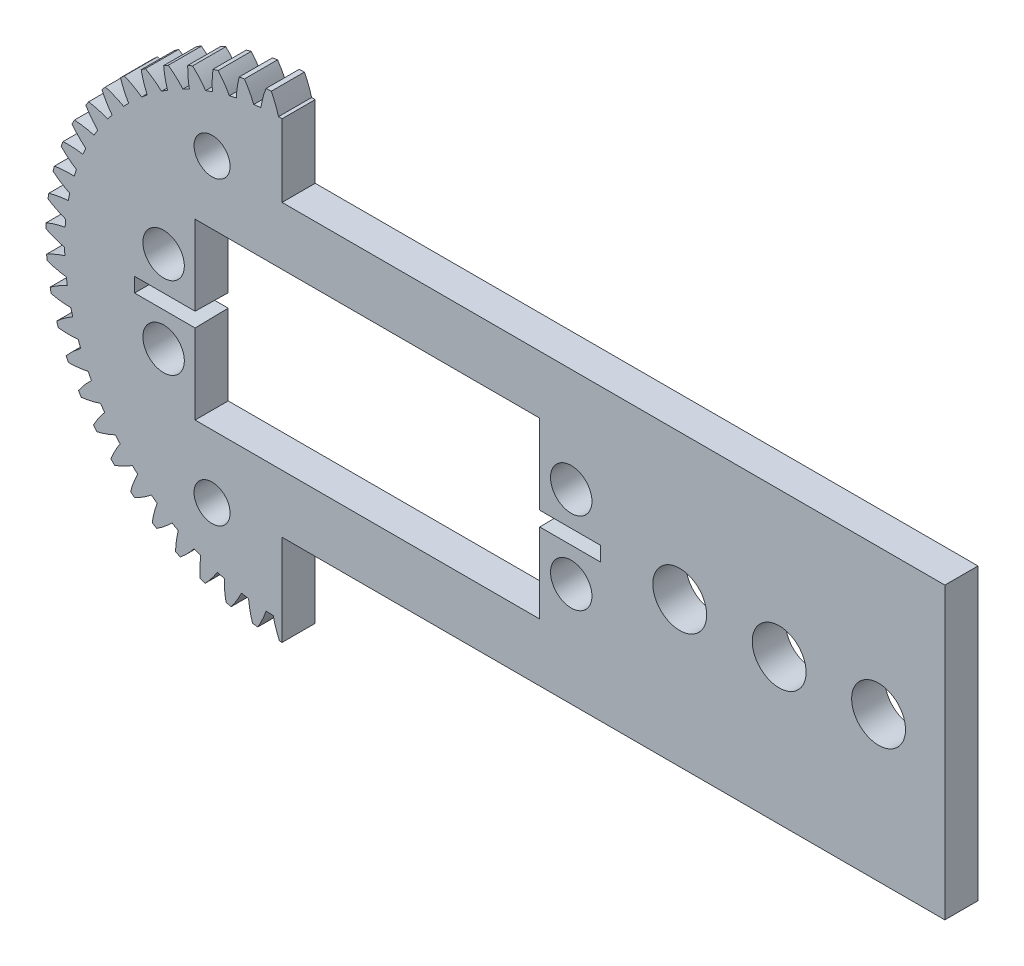
from build123d import *

# Parameters (mm, degrees)
MODEL_R                 = 2.5
BOSS_EXTRUDE1_DEPTH     = 4
SKETCH2_W               = 43.829603181
SKETCH2_H               = 63.068349784
CUT_EXTRUDE2_DEPTH      = 4
SKETCH4_W               = 80
SKETCH4_H               = 35
BOSS_EXTRUDE3_DEPTH     = 4
SKETCH5_W               = 41.6
SKETCH5_H               = 21
CUT_EXTRUDE3_DEPTH      = 4
SKETCH6_R               = 2.5
CUT_EXTRUDE4_DEPTH      = 4
SKETCH7_R               = 2.175
CUT_EXTRUDE5_DEPTH      = 4
SKETCH8_R               = 3.25
CUT_EXTRUDE6_DEPTH      = 400
LPATTERN1_COUNT         = 3
LPATTERN1_PITCH         = 12
SKETCH9_W               = 9
SKETCH9_H               = 1.75
CUT_EXTRUDE_THIN1_DEPTH = 5
CUT_EXTRUDE_THIN1_TAPER = 1


with BuildPart() as part:
    # Model → Boss-Extrude1 (new body)
    with BuildSketch(Plane.XY):
        with BuildLine():
            ThreePointArc((-28.477434739, 1.133891841), (-28.488377496, 0.813847448), (-28.495723539, 0.493700304))
            ThreePointArc((-28.495723539, 0.493700304), (-27.393467785, 0.027569431), (-26.247097137, -0.316058386))
            ThreePointArc((-26.247097137, -0.316058386), (-26.23829547, -0.749567777), (-26.222334246, -1.182872637))
            ThreePointArc((-26.222334246, -1.182872637), (-27.34721798, -1.591384969), (-28.421065212, -2.119682102))
            ThreePointArc((-28.421065212, -2.119682102), (-28.39545433, -2.438887742), (-28.366258465, -2.757785467))
            ThreePointArc((-28.366258465, -2.757785467), (-27.21805259, -3.095230288), (-26.03998367, -3.305941842))
            ThreePointArc((-26.03998367, -3.305941842), (-25.981823028, -3.73562219), (-25.916572812, -4.164283211))
            ThreePointArc((-25.916572812, -4.164283211), (-26.987557359, -4.698359835), (-27.994183636, -5.345622747))
            ThreePointArc((-27.994183636, -5.345622747), (-27.932352991, -5.659828299), (-27.866995832, -5.973319287))
            ThreePointArc((-27.866995832, -5.973319287), (-26.687808456, -6.177678948), (-25.493399194, -6.25272729))
            ThreePointArc((-25.493399194, -6.25272729), (-25.386637789, -6.672977054), (-25.272949217, -7.091405986))
            ThreePointArc((-25.272949217, -7.091405986), (-26.276072656, -7.744084395), (-27.202355065, -8.501875025))
            ThreePointArc((-27.202355065, -8.501875025), (-27.105110714, -8.80698434), (-27.004444291, -9.110981755))
            ThreePointArc((-27.004444291, -9.110981755), (-25.809647924, -9.179592114), (-24.614469271, -9.117998876))
            ThreePointArc((-24.614469271, -9.117998876), (-24.460498903, -9.523339458), (-24.29985408, -9.926081438))
            ThreePointArc((-24.29985408, -9.926081438), (-25.222039162, -10.688852972), (-26.055902194, -11.54729236))
            ThreePointArc((-26.055902194, -11.54729236), (-25.924511868, -11.839327871), (-25.78984852, -12.129868643))
            ThreePointArc((-25.78984852, -12.129868643), (-24.595019161, -12.061835259), (-23.414652099, -11.864403402))
            ThreePointArc((-23.414652099, -11.864403402), (-23.215480006, -12.249550567), (-23.009973182, -12.631355239))
            ThreePointArc((-23.009973182, -12.631355239), (-23.839197815, -13.494276004), (-24.569770792, -14.442173079))
            ThreePointArc((-24.569770792, -14.442173079), (-24.405947362, -14.717327657), (-24.239042634, -14.990624143))
            ThreePointArc((-24.239042634, -14.990624143), (-23.05975671, -14.786833935), (-21.909589129, -14.456137285))
            ThreePointArc((-21.909589129, -14.456137285), (-21.667811823, -14.816070052), (-21.420122094, -15.171960007))
            ThreePointArc((-21.420122094, -15.171960007), (-22.145576068, -16.123780511), (-22.763334852, -17.148777986))
            ThreePointArc((-22.763334852, -17.148777986), (-22.569214009, -17.40346457), (-22.372243758, -17.655953932))
            ThreePointArc((-22.372243758, -17.655953932), (-21.223875065, -17.319063617), (-20.118901158, -16.859413312))
            ThreePointArc((-20.118901158, -16.859413312), (-19.837670577, -17.189439405), (-19.551026958, -17.514775074))
            ThreePointArc((-19.551026958, -17.514775074), (-20.163252869, -18.543086881), (-20.660144031, -19.631822346))
            ThreePointArc((-20.660144031, -19.631822346), (-20.438256436, -19.862720707), (-20.213788471, -20.09111136))
            ThreePointArc((-20.213788471, -20.09111136), (-19.111307751, -19.625512819), (-18.065932542, -19.042901102))
            ThreePointArc((-18.065932542, -19.042901102), (-17.748914957, -19.338718128), (-17.427054285, -19.629258263))
            ThreePointArc((-17.427054285, -19.629258263), (-17.918070833, -20.720655756), (-18.287616636, -21.858935879))
            ThreePointArc((-18.287616636, -21.858935879), (-18.040854934, -22.063035903), (-17.791815538, -22.264350426))
            ThreePointArc((-17.791815538, -22.264350426), (-16.749595313, -21.676113448), (-15.777446868, -20.978135554))
            ThreePointArc((-15.777446868, -20.978135554), (-15.428775087, -21.235887085), (-15.075893309, -21.487844051))
            ThreePointArc((-15.075893309, -21.487844051), (-15.439299342, -22.628099195), (-15.676682192, -23.801084754))
            ThreePointArc((-15.676682192, -23.801084754), (-15.408263298, -23.975725686), (-15.13789908, -24.147339635))
            ThreePointArc((-15.13789908, -24.147339635), (-14.169526285, -23.444132788), (-13.283278045, -22.639887928))
            ThreePointArc((-13.283278045, -22.639887928), (-12.907497539, -22.856213778), (-12.528195008, -23.06630293))
            ThreePointArc((-12.528195008, -23.06630293), (-12.759252972, -24.240550755), (-12.86137822, -25.43295009))
            ThreePointArc((-12.86137822, -25.43295009), (-12.574801385, -25.575855218), (-12.286636957, -25.715531343))
            ThreePointArc((-12.286636957, -25.715531343), (-11.404735812, -24.906522005), (-10.615941378, -24.006494739))
            ThreePointArc((-10.615941378, -24.006494739), (-10.217951021, -24.178574771), (-9.817172525, -24.344057275))
            ThreePointArc((-9.817172525, -24.344057275), (-9.912870228, -25.536989666), (-9.878406515, -26.733258027))
            ThreePointArc((-9.878406515, -26.733258027), (-9.577407707, -26.842564364), (-9.275199732, -26.948481774))
            ThreePointArc((-9.275199732, -26.948481774), (-8.491267167, -26.044216618), (-7.810209681, -25.060140178))
            ThreePointArc((-7.810209681, -25.060140178), (-7.395197884, -25.185731064), (-6.978168185, -25.304449604))
            ThreePointArc((-6.978168185, -25.304449604), (-6.93725806, -26.500514862), (-6.766654673, -27.685057062))
            ThreePointArc((-6.766654673, -27.685057062), (-6.455157872, -27.759339633), (-6.142846094, -27.830117532))
            ThreePointArc((-6.142846094, -27.830117532), (-5.467101869, -26.842385037), (-4.902659956, -25.787088365))
            ThreePointArc((-4.902659956, -25.787088365), (-4.476037034, -25.864552837), (-4.048192751, -25.934959735))
            ThreePointArc((-4.048192751, -25.934959735), (-3.871208124, -27.11856532), (-3.56668914, -28.27593904))
            ThreePointArc((-3.56668914, -28.27593904), (-3.248755182, -28.314229457), (-2.930411062, -28.348945148))
            ThreePointArc((-2.930411062, -28.348945148), (-2.371664537, -27.290621918), (-1.931196562, -26.177862419))
            ThreePointArc((-1.931196562, -26.177862419), (-1.498524196, -26.206190609), (-1.065442934, -26.227368003))
            ThreePointArc((-1.065442934, -26.227368003), (-0.75469107, -27.383083806), (-0.320226359, -28.498200909))
            ThreePointArc((-0.320226359, -28.498200909), (0, -28.5), (0.320226359, -28.49820091))
            ThreePointArc((0.320226359, -28.49820091), (0.75469107, -27.383083806), (1.065442934, -26.227368003))
            ThreePointArc((1.065442934, -26.227368003), (1.498524196, -26.206190609), (1.931196562, -26.177862419))
            ThreePointArc((1.931196562, -26.177862419), (2.371664537, -27.290621918), (2.930411062, -28.348945148))
            ThreePointArc((2.930411062, -28.348945148), (3.248755182, -28.314229457), (3.56668914, -28.27593904))
            ThreePointArc((3.56668914, -28.27593904), (3.871208124, -27.11856532), (4.048192751, -25.934959735))
            ThreePointArc((4.048192751, -25.934959735), (4.476037034, -25.864552837), (4.902659956, -25.787088365))
            ThreePointArc((4.902659956, -25.787088365), (5.467101869, -26.842385037), (6.142846094, -27.830117532))
            ThreePointArc((6.142846094, -27.830117532), (6.455157872, -27.759339633), (6.766654673, -27.685057062))
            ThreePointArc((6.766654673, -27.685057062), (6.93725806, -26.500514862), (6.978168185, -25.304449604))
            ThreePointArc((6.978168185, -25.304449604), (7.395197884, -25.185731064), (7.810209681, -25.060140178))
            ThreePointArc((7.810209681, -25.060140178), (8.491267167, -26.044216618), (9.275199732, -26.948481774))
            ThreePointArc((9.275199732, -26.948481774), (9.577407707, -26.842564364), (9.878406515, -26.733258027))
            ThreePointArc((9.878406515, -26.733258027), (9.912870228, -25.536989666), (9.817172525, -24.344057275))
            ThreePointArc((9.817172525, -24.344057275), (10.217951021, -24.178574771), (10.615941378, -24.006494739))
            ThreePointArc((10.615941378, -24.006494739), (11.404735812, -24.906522005), (12.286636957, -25.715531343))
            ThreePointArc((12.286636957, -25.715531343), (12.574801385, -25.575855218), (12.86137822, -25.43295009))
            ThreePointArc((12.86137822, -25.43295009), (12.759252972, -24.240550755), (12.528195008, -23.06630293))
            ThreePointArc((12.528195008, -23.06630293), (12.907497539, -22.856213778), (13.283278045, -22.639887928))
            ThreePointArc((13.283278045, -22.639887928), (14.169526285, -23.444132788), (15.13789908, -24.147339635))
            ThreePointArc((15.13789908, -24.147339635), (15.408263297, -23.975725686), (15.676682191, -23.801084754))
            ThreePointArc((15.676682191, -23.801084754), (15.439299342, -22.628099195), (15.075893309, -21.487844051))
            ThreePointArc((15.075893309, -21.487844051), (15.428775087, -21.235887085), (15.777446868, -20.978135554))
            ThreePointArc((15.777446868, -20.978135554), (16.749595313, -21.676113448), (17.791815538, -22.264350426))
            ThreePointArc((17.791815538, -22.264350426), (18.040854934, -22.063035903), (18.287616636, -21.858935879))
            ThreePointArc((18.287616636, -21.858935879), (17.918070833, -20.720655756), (17.427054285, -19.629258263))
            ThreePointArc((17.427054285, -19.629258263), (17.748914957, -19.338718128), (18.065932542, -19.042901102))
            ThreePointArc((18.065932542, -19.042901102), (19.111307751, -19.625512819), (20.213788471, -20.09111136))
            ThreePointArc((20.213788471, -20.09111136), (20.438256436, -19.862720707), (20.660144031, -19.631822346))
            ThreePointArc((20.660144031, -19.631822346), (20.163252869, -18.543086881), (19.551026958, -17.514775074))
            ThreePointArc((19.551026958, -17.514775074), (19.837670577, -17.189439405), (20.118901158, -16.859413312))
            ThreePointArc((20.118901158, -16.859413312), (21.223875065, -17.319063617), (22.372243758, -17.655953932))
            ThreePointArc((22.372243758, -17.655953932), (22.569214009, -17.40346457), (22.763334852, -17.148777986))
            ThreePointArc((22.763334852, -17.148777986), (22.145576068, -16.123780511), (21.420122094, -15.171960007))
            ThreePointArc((21.420122094, -15.171960007), (21.667811823, -14.816070052), (21.909589129, -14.456137285))
            ThreePointArc((21.909589129, -14.456137285), (23.05975671, -14.786833935), (24.239042634, -14.990624143))
            ThreePointArc((24.239042634, -14.990624143), (24.405947362, -14.717327657), (24.569770792, -14.442173079))
            ThreePointArc((24.569770792, -14.442173079), (23.839197815, -13.494276004), (23.009973182, -12.631355239))
            ThreePointArc((23.009973182, -12.631355239), (23.215480006, -12.249550567), (23.414652099, -11.864403402))
            ThreePointArc((23.414652099, -11.864403402), (24.595019161, -12.061835259), (25.78984852, -12.129868643))
            ThreePointArc((25.78984852, -12.129868643), (25.924511868, -11.839327871), (26.055902194, -11.54729236))
            ThreePointArc((26.055902194, -11.54729236), (25.222039162, -10.688852972), (24.29985408, -9.926081438))
            ThreePointArc((24.29985408, -9.926081438), (24.460498903, -9.523339458), (24.614469271, -9.117998876))
            ThreePointArc((24.614469271, -9.117998876), (25.809647924, -9.179592114), (27.004444291, -9.110981756))
            ThreePointArc((27.004444291, -9.110981756), (27.105110714, -8.80698434), (27.202355065, -8.501875025))
            ThreePointArc((27.202355065, -8.501875025), (26.276072656, -7.744084395), (25.272949217, -7.091405986))
            ThreePointArc((25.272949217, -7.091405986), (25.386637789, -6.672977054), (25.493399194, -6.25272729))
            ThreePointArc((25.493399194, -6.25272729), (26.687808456, -6.177678948), (27.866995832, -5.973319287))
            ThreePointArc((27.866995832, -5.973319287), (27.932352991, -5.659828299), (27.994183636, -5.345622747))
            ThreePointArc((27.994183636, -5.345622747), (26.987557359, -4.698359835), (25.916572812, -4.164283211))
            ThreePointArc((25.916572812, -4.164283211), (25.981823028, -3.73562219), (26.03998367, -3.305941842))
            ThreePointArc((26.03998367, -3.305941842), (27.21805259, -3.095230288), (28.366258465, -2.757785467))
            ThreePointArc((28.366258465, -2.757785467), (28.39545433, -2.438887742), (28.421065212, -2.119682102))
            ThreePointArc((28.421065212, -2.119682102), (27.34721798, -1.591384969), (26.222334246, -1.182872637))
            ThreePointArc((26.222334246, -1.182872637), (26.23829547, -0.749567777), (26.247097137, -0.316058386))
            ThreePointArc((26.247097137, -0.316058386), (27.393467785, 0.027569431), (28.495723539, 0.493700304))
            ThreePointArc((28.495723539, 0.493700304), (28.488377496, 0.813847448), (28.477434739, 1.133891841))
            ThreePointArc((28.477434739, 1.133891841), (27.350365792, 1.536336033), (26.186247451, 1.813958491))
            ThreePointArc((26.186247451, 1.813958491), (26.152711603, 2.246258398), (26.112039552, 2.677945375))
            ThreePointArc((26.112039552, 2.677945375), (27.211767234, 3.150009741), (28.253703278, 3.738749937))
            ThreePointArc((28.253703278, 3.738749937), (28.209911094, 4.055972891), (28.162557353, 4.37268377))
            ThreePointArc((28.162557353, 4.37268377), (26.996959759, 4.644028546), (25.808782875, 4.787141897))
            ThreePointArc((25.808782875, 4.787141897), (25.726187146, 5.212801159), (25.636571599, 5.637038022))
            ThreePointArc((25.636571599, 5.637038022), (26.675319682, 6.231384856), (27.643352786, 6.935059247))
            ThreePointArc((27.643352786, 6.935059247), (27.563685359, 7.245222525), (27.480537963, 7.554471079))
            ThreePointArc((27.480537963, 7.554471079), (26.291607069, 7.691179044), (25.094861343, 7.697917586))
            ThreePointArc((25.094861343, 7.697917586), (24.964282496, 8.111387085), (24.826891729, 8.522643257))
            ThreePointArc((24.826891729, 8.522643257), (25.791118543, 9.23152434), (26.672628915, 10.040959454))
            ThreePointArc((26.672628915, 10.040959454), (26.558124833, 10.340019602), (26.440267734, 10.637774304))
            ThreePointArc((26.440267734, 10.637774304), (25.243503073, 10.638063262), (24.053789917, 10.508339148))
            ThreePointArc((24.053789917, 10.508339148), (23.876930246, 10.904228676), (23.693555357, 11.297142804))
            ThreePointArc((23.693555357, 11.297142804), (24.570690732, 12.111316787), (25.354186536, 13.015960398))
            ThreePointArc((25.354186536, 13.015960398), (25.206338533, 13.300018712), (25.055308181, 13.582397872))
            ThreePointArc((25.055308181, 13.582397872), (23.866311409, 13.446264056), (22.699140553, 13.181768438))
            ThreePointArc((22.699140553, 13.181768438), (22.478305695, 13.554916971), (22.251337257, 13.924366818))
            ThreePointArc((22.251337257, 13.924366818), (23.029946391, 14.833219697), (23.705213562, 15.821278393))
            ThreePointArc((23.705213562, 15.821278393), (23.525949063, 16.086631738), (23.343714368, 16.349954113))
            ThreePointArc((23.343714368, 16.349954113), (22.177985878, 16.079172235), (21.048573179, 15.683353218))
            ThreePointArc((21.048573179, 15.683353218), (20.786642053, 16.028896193), (20.519038946, 16.370065416))
            ThreePointArc((20.519038946, 16.370065416), (21.188971479, 17.361748904), (21.747206876, 18.420341829))
            ThreePointArc((21.747206876, 18.420341829), (21.538862869, 18.663530917), (21.327799539, 18.904363698))
            ThreePointArc((21.327799539, 18.904363698), (20.200536383, 18.502463814), (19.123605463, 17.980481504))
            ThreePointArc((19.123605463, 17.980481504), (18.823992743, 18.29391424), (18.519243583, 18.602355176))
            ThreePointArc((18.519243583, 18.602355176), (19.071765919, 19.663941163), (19.50569209, 20.779267939))
            ThreePointArc((19.50569209, 20.779267939), (19.270984658, 20.997122429), (19.033844226, 21.212325992))
            ThreePointArc((19.033844226, 21.212325992), (17.959742004, 20.684547481), (16.949332304, 20.043206715))
            ThreePointArc((16.949332304, 20.043206715), (16.6159439, 20.320443138), (16.278021558, 20.592134788))
            ThreePointArc((16.278021558, 20.592134788), (16.705930724, 21.709783877), (17.009890778, 22.867304514))
            ThreePointArc((17.009890778, 22.867304514), (16.75187969, 23.05698434), (16.491753645, 23.243753176))
            ThreePointArc((16.491753645, 23.243753176), (15.484814923, 22.596976438), (14.554098679, 21.844638076))
            ThreePointArc((14.554098679, 21.844638076), (14.191280817, 22.082063983), (13.824590629, 22.313464432))
            ThreePointArc((13.824590629, 22.313464432), (14.122308174, 23.472606357), (14.292339526, 24.657230803))
            ThreePointArc((14.292339526, 24.657230803), (14.014388352, 24.816263198), (13.734667835, 24.972162491))
            ThreePointArc((13.734667835, 24.972162491), (12.808019598, 24.21481925), (11.969130119, 23.361291171))
            ThreePointArc((11.969130119, 23.361291171), (11.581612687, 23.555811355), (11.190935018, 23.743903942))
            ThreePointArc((11.190935018, 23.743903942), (11.354579739, 24.929427516), (11.388465771, 26.12571238))
            ThreePointArc((11.388465771, 26.12571238), (11.09419803, 26.252024114), (10.798529624, 26.375021478))
            ThreePointArc((10.798529624, 26.375021478), (9.96425215, 25.516984862), (9.228125644, 24.57339411))
            ThreePointArc((9.228125644, 24.57339411), (8.820960523, 24.722472701), (8.411388455, 24.864805353))
            ThreePointArc((8.411388455, 24.864805353), (8.438826993, 26.061255463), (8.336125949, 27.253605342))
            ThreePointArc((8.336125949, 27.253605342), (8.02937787, 27.345549748), (7.721616066, 27.434041724))
            ThreePointArc((7.721616066, 27.434041724), (6.990585436, 26.486497552), (6.366818438, 25.465145277))
            ThreePointArc((6.366818438, 25.465145277), (5.945313648, 25.566838808), (5.522186581, 25.661556001))
            ThreePointArc((5.522186581, 25.661556001), (5.413061232, 26.85333509), (5.175111976, 28.02620588))
            ThreePointArc((5.175111976, 28.02620588), (4.85988249, 28.082584322), (4.544039434, 28.135417282))
            ThreePointArc((4.544039434, 28.135417282), (3.925785751, 27.110718242), (3.422510017, 26.024919331))
            ThreePointArc((3.422510017, 26.024919331), (2.992160518, 26.077902071), (2.560994558, 26.123769021))
            ThreePointArc((2.560994558, 26.123769021), (2.316727939, 27.295340426), (1.946632505, 28.433441963))
            ThreePointArc((1.946632505, 28.433441963), (1.62703111, 28.453519462), (1.307224299, 28.470004648))
            ThreePointArc((1.307224299, 28.470004648), (0.809807445, 27.381509258), (0.433583944, 26.245418761))
            ThreePointArc((0.433583944, 26.245418761), (0, 26.249), (-0.433583944, 26.245418761))
            ThreePointArc((-0.433583944, 26.245418761), (-0.809807445, 27.381509258), (-1.307224299, 28.470004648))
            ThreePointArc((-1.307224299, 28.470004648), (-1.62703111, 28.453519462), (-1.946632505, 28.433441964))
            ThreePointArc((-1.946632505, 28.433441964), (-2.316727939, 27.295340426), (-2.560994558, 26.123769021))
            ThreePointArc((-2.560994558, 26.123769021), (-2.992160518, 26.077902071), (-3.422510017, 26.024919331))
            ThreePointArc((-3.422510017, 26.024919331), (-3.925785751, 27.110718242), (-4.544039434, 28.135417282))
            ThreePointArc((-4.544039434, 28.135417282), (-4.85988249, 28.082584322), (-5.175111976, 28.02620588))
            ThreePointArc((-5.175111976, 28.02620588), (-5.413061232, 26.85333509), (-5.522186581, 25.661556001))
            ThreePointArc((-5.522186581, 25.661556001), (-5.945313648, 25.566838808), (-6.366818438, 25.465145277))
            ThreePointArc((-6.366818438, 25.465145277), (-6.990585436, 26.486497552), (-7.721616066, 27.434041724))
            ThreePointArc((-7.721616066, 27.434041724), (-8.02937787, 27.345549748), (-8.336125949, 27.253605342))
            ThreePointArc((-8.336125949, 27.253605342), (-8.438826993, 26.061255463), (-8.411388455, 24.864805353))
            ThreePointArc((-8.411388455, 24.864805353), (-8.820960522, 24.722472701), (-9.228125643, 24.573394111))
            ThreePointArc((-9.228125643, 24.573394111), (-9.96425215, 25.516984862), (-10.798529624, 26.375021478))
            ThreePointArc((-10.798529624, 26.375021478), (-11.09419803, 26.252024114), (-11.388465771, 26.12571238))
            ThreePointArc((-11.388465771, 26.12571238), (-11.354579739, 24.929427516), (-11.190935018, 23.743903942))
            ThreePointArc((-11.190935018, 23.743903942), (-11.581612687, 23.555811355), (-11.969130119, 23.361291171))
            ThreePointArc((-11.969130119, 23.361291171), (-12.808019598, 24.21481925), (-13.734667835, 24.972162491))
            ThreePointArc((-13.734667835, 24.972162491), (-14.014388352, 24.816263198), (-14.292339526, 24.657230803))
            ThreePointArc((-14.292339526, 24.657230803), (-14.122308174, 23.472606357), (-13.824590629, 22.313464432))
            ThreePointArc((-13.824590629, 22.313464432), (-14.191280817, 22.082063983), (-14.554098678, 21.844638076))
            ThreePointArc((-14.554098678, 21.844638076), (-15.484814923, 22.596976438), (-16.491753645, 23.243753176))
            ThreePointArc((-16.491753645, 23.243753176), (-16.75187969, 23.05698434), (-17.009890778, 22.867304514))
            ThreePointArc((-17.009890778, 22.867304514), (-16.705930724, 21.709783877), (-16.278021558, 20.592134788))
            ThreePointArc((-16.278021558, 20.592134788), (-16.6159439, 20.320443138), (-16.949332304, 20.043206715))
            ThreePointArc((-16.949332304, 20.043206715), (-17.959742004, 20.684547481), (-19.033844226, 21.212325992))
            ThreePointArc((-19.033844226, 21.212325992), (-19.270984658, 20.99712243), (-19.50569209, 20.779267939))
            ThreePointArc((-19.50569209, 20.779267939), (-19.071765919, 19.663941163), (-18.519243583, 18.602355176))
            ThreePointArc((-18.519243583, 18.602355176), (-18.823992743, 18.29391424), (-19.123605463, 17.980481503))
            ThreePointArc((-19.123605463, 17.980481503), (-20.200536383, 18.502463814), (-21.327799539, 18.904363698))
            ThreePointArc((-21.327799539, 18.904363698), (-21.538862869, 18.663530917), (-21.747206876, 18.420341829))
            ThreePointArc((-21.747206876, 18.420341829), (-21.188971479, 17.361748904), (-20.519038946, 16.370065416))
            ThreePointArc((-20.519038946, 16.370065416), (-20.786642053, 16.028896193), (-21.048573178, 15.683353218))
            ThreePointArc((-21.048573178, 15.683353218), (-22.177985878, 16.079172235), (-23.343714368, 16.349954113))
            ThreePointArc((-23.343714368, 16.349954113), (-23.525949063, 16.086631738), (-23.705213562, 15.821278393))
            ThreePointArc((-23.705213562, 15.821278393), (-23.029946391, 14.833219697), (-22.251337257, 13.924366818))
            ThreePointArc((-22.251337257, 13.924366818), (-22.478305695, 13.554916971), (-22.699140553, 13.181768438))
            ThreePointArc((-22.699140553, 13.181768438), (-23.866311409, 13.446264056), (-25.055308181, 13.582397872))
            ThreePointArc((-25.055308181, 13.582397872), (-25.206338533, 13.300018712), (-25.354186536, 13.015960398))
            ThreePointArc((-25.354186536, 13.015960398), (-24.570690732, 12.111316787), (-23.693555357, 11.297142804))
            ThreePointArc((-23.693555357, 11.297142804), (-23.876930246, 10.904228676), (-24.053789917, 10.508339148))
            ThreePointArc((-24.053789917, 10.508339148), (-25.243503073, 10.638063262), (-26.440267734, 10.637774304))
            ThreePointArc((-26.440267734, 10.637774304), (-26.558124833, 10.340019602), (-26.672628915, 10.040959453))
            ThreePointArc((-26.672628915, 10.040959453), (-25.791118543, 9.23152434), (-24.826891729, 8.522643257))
            ThreePointArc((-24.826891729, 8.522643257), (-24.964282496, 8.111387085), (-25.094861343, 7.697917586))
            ThreePointArc((-25.094861343, 7.697917586), (-26.291607069, 7.691179044), (-27.480537963, 7.554471079))
            ThreePointArc((-27.480537963, 7.554471079), (-27.563685359, 7.245222524), (-27.643352786, 6.935059247))
            ThreePointArc((-27.643352786, 6.935059247), (-26.675319682, 6.231384856), (-25.636571599, 5.637038022))
            ThreePointArc((-25.636571599, 5.637038022), (-25.726187146, 5.212801159), (-25.808782875, 4.787141897))
            ThreePointArc((-25.808782875, 4.787141897), (-26.996959759, 4.644028546), (-28.162557353, 4.37268377))
            ThreePointArc((-28.162557353, 4.37268377), (-28.209911094, 4.055972891), (-28.253703278, 3.738749937))
            ThreePointArc((-28.253703278, 3.738749937), (-27.211767234, 3.150009741), (-26.112039552, 2.677945375))
            ThreePointArc((-26.112039552, 2.677945375), (-26.152711603, 2.246258398), (-26.186247452, 1.813958491))
            ThreePointArc((-26.186247452, 1.813958491), (-27.350365792, 1.536336033), (-28.477434739, 1.133891841))
        make_face()
        Circle(MODEL_R, mode=Mode.SUBTRACT)
    extrude(amount=BOSS_EXTRUDE1_DEPTH)

    # Sketch2 → Cut-Extrude2 (cut)
    with BuildSketch(Plane.XY):
        with Locations((21.914801591, 0)):
            Rectangle(SKETCH2_W, SKETCH2_H)
    extrude(amount=CUT_EXTRUDE2_DEPTH, mode=Mode.SUBTRACT)

    # Sketch4 → Boss-Extrude3 (add)
    with BuildSketch(Plane.XY):
        with Locations((40, 0)):
            Rectangle(SKETCH4_W, SKETCH4_H)
    extrude(amount=BOSS_EXTRUDE3_DEPTH)

    # Sketch5 → Cut-Extrude3 (cut)
    with BuildSketch(Plane.XY.offset(4)):
        with Locations((10.3, 0)):
            Rectangle(SKETCH5_W, SKETCH5_H)
    extrude(amount=-CUT_EXTRUDE3_DEPTH, mode=Mode.SUBTRACT)

    # Sketch6 → Cut-Extrude4 (cut)
    with BuildSketch(Plane.XY.offset(4)):
        with Locations((34.9, 4.95)):
            Circle(SKETCH6_R)
        with Locations((34.9, -4.95)):
            Circle(SKETCH6_R)
        with Locations((-14.3, -4.95)):
            Circle(SKETCH6_R)
        with Locations((-14.3, 4.95)):
            Circle(SKETCH6_R)
    extrude(amount=-CUT_EXTRUDE4_DEPTH, mode=Mode.SUBTRACT)

    # Sketch7 → Cut-Extrude5 (cut)
    with BuildSketch(Plane.XY.offset(4)):
        with Locations((-8.452365235, 18.126155741)):
            Circle(SKETCH7_R)
        with Locations((-8.452365235, -18.126155741)):
            Circle(SKETCH7_R)
    extrude(amount=-CUT_EXTRUDE5_DEPTH, mode=Mode.SUBTRACT)

    # Sketch8 → Cut-Extrude6 (cut)
    with BuildSketch(Plane.XY.offset(4)):
        with Locations((72, 0)):
            Circle(SKETCH8_R)
    cut_extrude6 = extrude(amount=-CUT_EXTRUDE6_DEPTH, mode=Mode.SUBTRACT)

    # LPattern1: Cut-Extrude6 ×3
    with Locations(*[(-i * LPATTERN1_PITCH, 0, 0) for i in range(1, LPATTERN1_COUNT)]):
        add(cut_extrude6, mode=Mode.SUBTRACT)

    # Sketch9 → Cut-Extrude-Thin1 (cut, through all)
    with BuildSketch(Plane.XY.offset(4)):
        with Locations((33.905764463, 0)):
            Rectangle(SKETCH9_W, SKETCH9_H)
        with Locations((-13.305764463, 0)):
            Rectangle(SKETCH9_W, SKETCH9_H)
    extrude(amount=-CUT_EXTRUDE_THIN1_DEPTH, taper=CUT_EXTRUDE_THIN1_TAPER, mode=Mode.SUBTRACT)


solid = part.part
